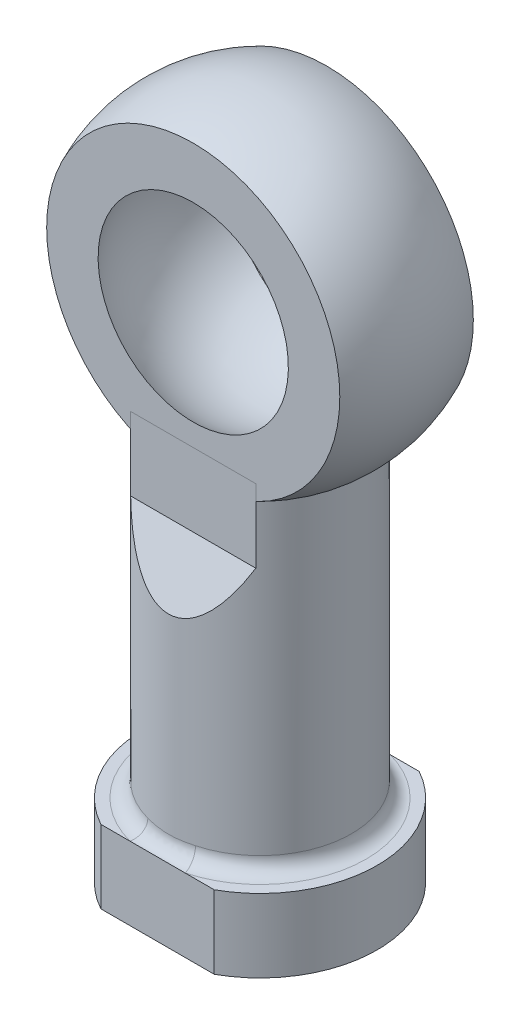
from build123d import *

# Parameters (mm, degrees)
SKETCH5_R               = 6.25
SKETCH5_R_2             = 3.4
EXTRUDE2_DEPTH          = 3
EXTRUDE2_DEPTH_BACK     = 25
SKETCH7_R               = 3.4
BOSS_EXTRUDE1_DEPTH     = 5
FILLET1_R               = 1
CUT_EXTRUDE1_DEPTH      = 12
CUT_EXTRUDE1_DEPTH_BACK = 12


with BuildPart() as part:
    # Sketch3 → Revolve2 (revolve)
    with BuildSketch(Plane(origin=(0, 0, 0), x_dir=(0, 0, -1), z_dir=(1, 0, 0))):
        with BuildLine():
            Line((-4.56, 10.01031468), (-4.56, 0))
            Line((-4.56, 0), (4.56, 0))
            Line((4.56, 0), (4.56, 10.01031468))
            ThreePointArc((4.56, 10.01031468), (0, 11), (-4.56, 10.01031468))
        make_face()
    revolve(axis=Axis((0, 0, 8.146649187), (0, 0, -1)))

    # Sketch2 → Cut-Revolve2 (revolve, cut)
    with BuildSketch(Plane(origin=(0, 0, 0), x_dir=(0, 0, -1), z_dir=(1, 0, 0))):
        with BuildLine():
            Line((0, 7.938), (0, -7.938))
            ThreePointArc((0, -7.938), (7.938, 0), (0, 7.938))
        make_face()
    revolve(axis=Axis((0, 15.474361319, 0), (0, -1, 0)), mode=Mode.SUBTRACT)


with BuildPart() as body_2:
    # Sketch5 → Extrude2 (new body, two sides)
    with BuildSketch(Plane(origin=(0, -11, 0), x_dir=(-1, 0, 0), z_dir=(0, 1, 0))) as extrude2_sk:
        Circle(SKETCH5_R)
        Circle(SKETCH5_R_2, mode=Mode.SUBTRACT)
    extrude(amount=EXTRUDE2_DEPTH)
    extrude(extrude2_sk.sketch, amount=-EXTRUDE2_DEPTH_BACK)

    # Sketch7 → Boss-Extrude1 (add)
    with BuildSketch(Plane.XZ.offset(36)):
        with BuildLine():
            Line((-3.872983346, 7), (3.872983346, 7))
            ThreePointArc((3.872983346, 7), (8, 0), (3.872983346, -7))
            Line((3.872983346, -7), (-3.872983346, -7))
            ThreePointArc((-3.872983346, -7), (-8, 0), (-3.872983346, 7))
        make_face()
        Circle(SKETCH7_R, mode=Mode.SUBTRACT)
    extrude(amount=-BOSS_EXTRUDE1_DEPTH)

    # Fillet1
    fillet1_edges = [body_2.edges().sort_by_distance(p)[0] for p in [
        (6.25, -31, 0),
    ]]
    fillet(fillet1_edges, radius=FILLET1_R)

    # Sketch8 → Cut-Extrude1 (cut, two sides)
    with BuildSketch(Plane(origin=(0, 0, 0), x_dir=(0, 0, -1), z_dir=(1, 0, 0))) as cut_extrude1_sk:
        Polygon((-4.56, 0), (-4.56, -13), (-6.25, -17), (-14.338899791, -17), (-14.338899791, 16.981131473), (14.338899791, 16.981131473), (14.338899791, -17), (6.25, -17), (4.56, -13), (4.56, 0), (4.56, 14.718656898), (-4.56, 14.718656898), align=None)
    extrude(amount=CUT_EXTRUDE1_DEPTH, mode=Mode.SUBTRACT)
    extrude(cut_extrude1_sk.sketch, amount=-CUT_EXTRUDE1_DEPTH_BACK, mode=Mode.SUBTRACT)


solid = Compound([part.part, body_2.part])
